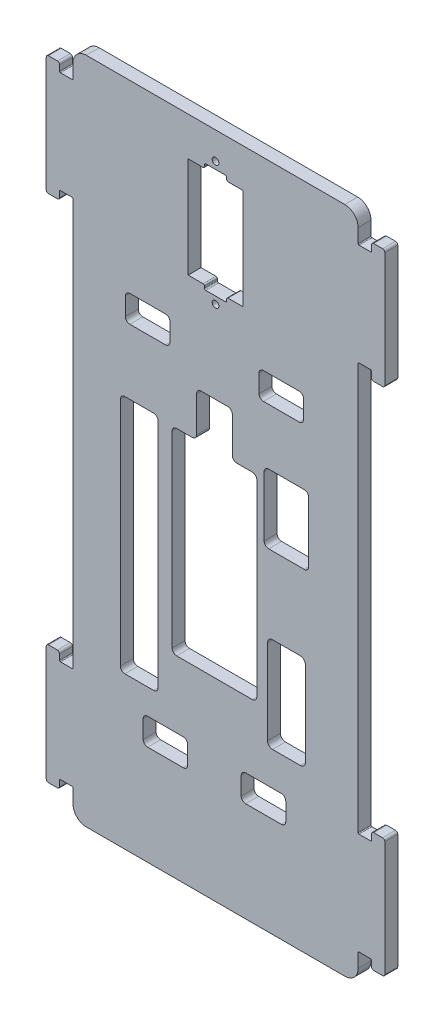
from build123d import *

# Parameters (mm, degrees)
EXTRUDE_1_DEPTH     = 1.45
SKETCH_2_R          = 0.75
SKETCH_2_W          = 12.3
SKETCH_2_H          = 22.6
CUT_EXTRUDE_1_DEPTH = 3.9
SKETCH_3_W          = 5
SKETCH_3_H          = 1
CUT_EXTRUDE_2_DEPTH = 3.9
FILLET_1_R          = 0.3
CUT_EXTRUDE_3_DEPTH = 3.9
CUT_EXTRUDE_4_DEPTH = 3.9
FILLET_2_R          = 1
CUT_EXTRUDE_5_DEPTH = 3.9


with BuildPart() as part:
    # 草图1 → 凸台-拉伸1 (new body, symmetric)
    with BuildSketch(Plane.XY):
        with BuildLine():
            Line((32.2, 68.7), (34.8, 68.7))
            ThreePointArc((34.8, 68.7), (34.941421356, 68.758578644), (35, 68.9))
            Line((35, 68.9), (35, 70.15))
            ThreePointArc((35, 70.15), (35.146446609, 70.503553391), (35.5, 70.65))
            Line((35.5, 70.65), (37.5, 70.65))
            ThreePointArc((37.5, 70.65), (37.853553391, 70.503553391), (38, 70.15))
            Line((38, 70.15), (38, 44.35))
            ThreePointArc((38, 44.35), (37.853553391, 43.996446609), (37.5, 43.85))
            Line((37.5, 43.85), (35.5, 43.85))
            ThreePointArc((35.5, 43.85), (35.146446609, 43.996446609), (35, 44.35))
            Line((35, 44.35), (35, 45.6))
            ThreePointArc((35, 45.6), (34.941421356, 45.741421356), (34.8, 45.8))
            Line((34.8, 45.8), (32.2, 45.8))
            ThreePointArc((32.2, 45.8), (32.058578644, 45.741421356), (32, 45.6))
            Line((32, 45.6), (32, -45.6))
            ThreePointArc((32, -45.6), (32.058578644, -45.741421356), (32.2, -45.8))
            Line((32.2, -45.8), (34.8, -45.8))
            ThreePointArc((34.8, -45.8), (34.941421356, -45.741421356), (35, -45.6))
            Line((35, -45.6), (35, -44.35))
            ThreePointArc((35, -44.35), (35.146446609, -43.996446609), (35.5, -43.85))
            Line((35.5, -43.85), (37.5, -43.85))
            ThreePointArc((37.5, -43.85), (37.853553391, -43.996446609), (38, -44.35))
            Line((38, -44.35), (38, -70.15))
            ThreePointArc((38, -70.15), (37.853553391, -70.503553391), (37.5, -70.65))
            Line((37.5, -70.65), (35.5, -70.65))
            ThreePointArc((35.5, -70.65), (35.146446609, -70.503553391), (35, -70.15))
            Line((35, -70.15), (35, -68.9))
            ThreePointArc((35, -68.9), (34.941421356, -68.758578644), (34.8, -68.7))
            Line((34.8, -68.7), (32.2, -68.7))
            ThreePointArc((32.2, -68.7), (32.058578644, -68.758578644), (32, -68.9))
            Line((32, -68.9), (32, -72))
            ThreePointArc((32, -72), (31.121320344, -74.121320344), (29, -75))
            Line((29, -75), (-29, -75))
            ThreePointArc((-29, -75), (-31.121320344, -74.121320344), (-32, -72))
            Line((-32, -72), (-32, -68.9))
            ThreePointArc((-32, -68.9), (-32.058578644, -68.758578644), (-32.2, -68.7))
            Line((-32.2, -68.7), (-34.8, -68.7))
            ThreePointArc((-34.8, -68.7), (-34.941421356, -68.758578644), (-35, -68.9))
            Line((-35, -68.9), (-35, -70.15))
            ThreePointArc((-35, -70.15), (-35.146446609, -70.503553391), (-35.5, -70.65))
            Line((-35.5, -70.65), (-37.5, -70.65))
            ThreePointArc((-37.5, -70.65), (-37.853553391, -70.503553391), (-38, -70.15))
            Line((-38, -70.15), (-38, -44.35))
            ThreePointArc((-38, -44.35), (-37.853553391, -43.996446609), (-37.5, -43.85))
            Line((-37.5, -43.85), (-35.5, -43.85))
            ThreePointArc((-35.5, -43.85), (-35.146446609, -43.996446609), (-35, -44.35))
            Line((-35, -44.35), (-35, -45.6))
            ThreePointArc((-35, -45.6), (-34.941421356, -45.741421356), (-34.8, -45.8))
            Line((-34.8, -45.8), (-32.2, -45.8))
            ThreePointArc((-32.2, -45.8), (-32.058578644, -45.741421356), (-32, -45.6))
            Line((-32, -45.6), (-32, 45.6))
            ThreePointArc((-32, 45.6), (-32.058578644, 45.741421356), (-32.2, 45.8))
            Line((-32.2, 45.8), (-34.8, 45.8))
            ThreePointArc((-34.8, 45.8), (-34.941421356, 45.741421356), (-35, 45.6))
            Line((-35, 45.6), (-35, 44.35))
            ThreePointArc((-35, 44.35), (-35.146446609, 43.996446609), (-35.5, 43.85))
            Line((-35.5, 43.85), (-37.5, 43.85))
            ThreePointArc((-37.5, 43.85), (-37.853553391, 43.996446609), (-38, 44.35))
            Line((-38, 44.35), (-38, 70.15))
            ThreePointArc((-38, 70.15), (-37.853553391, 70.503553391), (-37.5, 70.65))
            Line((-37.5, 70.65), (-35.5, 70.65))
            ThreePointArc((-35.5, 70.65), (-35.146446609, 70.503553391), (-35, 70.15))
            Line((-35, 70.15), (-35, 68.9))
            ThreePointArc((-35, 68.9), (-34.941421356, 68.758578644), (-34.8, 68.7))
            Line((-34.8, 68.7), (-32.2, 68.7))
            ThreePointArc((-32.2, 68.7), (-32.058578644, 68.758578644), (-32, 68.9))
            Line((-32, 68.9), (-32, 72))
            ThreePointArc((-32, 72), (-31.121320344, 74.121320344), (-29, 75))
            Line((-29, 75), (29, 75))
            ThreePointArc((29, 75), (31.121320344, 74.121320344), (32, 72))
            Line((32, 72), (32, 68.9))
            ThreePointArc((32, 68.9), (32.058578644, 68.758578644), (32.2, 68.7))
        make_face()
    extrude(amount=EXTRUDE_1_DEPTH, both=True)

    # 草图2 → 切除-拉伸1 (cut, through all)
    with BuildSketch(Plane.XY.offset(1.45)):
        with Locations((0, 41.1)):
            Circle(SKETCH_2_R)
        with Locations((0, 68.9)):
            Circle(SKETCH_2_R)
        with Locations((0, 55)):
            Rectangle(SKETCH_2_W, SKETCH_2_H)
    extrude(amount=-CUT_EXTRUDE_1_DEPTH, mode=Mode.SUBTRACT)

    # 草图3 → 切除-拉伸2 (cut, through all)
    with BuildSketch(Plane.XY.offset(1.45)):
        with Locations((0, 66.8)):
            Rectangle(SKETCH_3_W, SKETCH_3_H)
        with Locations((0, 43.2)):
            Rectangle(SKETCH_3_W, SKETCH_3_H)
    extrude(amount=-CUT_EXTRUDE_2_DEPTH, mode=Mode.SUBTRACT)

    # 圆角1
    fillet_1_edges = [part.edges().sort_by_distance(p)[0] for p in [
        (2.5, 66.3, 0),
        (-2.5, 66.3, 0),
        (-2.5, 67.3, 0),
        (2.5, 67.3, 0),
        (-2.5, 43.7, 0),
        (2.5, 43.7, 0),
        (2.5, 42.7, 0),
        (-2.5, 42.7, 0),
    ]]
    fillet(fillet_1_edges, radius=FILLET_1_R)

    # 草图4 → 切除-拉伸3 (cut, through all)
    with BuildSketch(Plane.XY.offset(1.45)):
        with BuildLine():
            Line((-20.36, 12.99), (-13.89, 12.99))
            ThreePointArc((-13.89, 12.99), (-13.182893219, 12.697106781), (-12.89, 11.99))
            Line((-12.89, 11.99), (-12.89, -39.9))
            ThreePointArc((-12.89, -39.9), (-13.182893219, -40.607106781), (-13.89, -40.9))
            Line((-13.89, -40.9), (-20.36, -40.9))
            ThreePointArc((-20.36, -40.9), (-21.067106781, -40.607106781), (-21.36, -39.9))
            Line((-21.36, -39.9), (-21.36, 11.99))
            ThreePointArc((-21.36, 11.99), (-21.067106781, 12.697106781), (-20.36, 12.99))
        make_face()
        with BuildLine():
            Line((-8.74, 12.6), (8.26, 12.6))
            ThreePointArc((8.26, 12.6), (8.967106781, 12.307106781), (9.26, 11.6))
            Line((9.26, 11.6), (9.26, -30.6))
            ThreePointArc((9.26, -30.6), (8.967106781, -31.307106781), (8.26, -31.6))
            Line((8.26, -31.6), (-8.74, -31.6))
            ThreePointArc((-8.74, -31.6), (-9.447106781, -31.307106781), (-9.74, -30.6))
            Line((-9.74, -30.6), (-9.74, 11.6))
            ThreePointArc((-9.74, 11.6), (-9.447106781, 12.307106781), (-8.74, 12.6))
        make_face()
        with BuildLine():
            Line((11.91, 15.03), (19.91, 15.03))
            ThreePointArc((19.91, 15.03), (20.617106781, 14.737106781), (20.91, 14.03))
            Line((20.91, 14.03), (20.91, 0.53))
            ThreePointArc((20.91, 0.53), (20.617106781, -0.177106781), (19.91, -0.47))
            Line((19.91, -0.47), (11.91, -0.47))
            ThreePointArc((11.91, -0.47), (11.202893219, -0.177106781), (10.91, 0.53))
            Line((10.91, 0.53), (10.91, 14.03))
            ThreePointArc((10.91, 14.03), (11.202893219, 14.737106781), (11.91, 15.03))
        make_face()
        with BuildLine():
            Line((12.801778644, -17.71), (19.028221356, -17.71))
            ThreePointArc((19.028221356, -17.71), (19.821438642, -18.038561358), (20.15, -18.831778644))
            Line((20.15, -18.831778644), (20.15, -37.908221356))
            ThreePointArc((20.15, -37.908221356), (19.821438642, -38.701438642), (19.028221356, -39.03))
            Line((19.028221356, -39.03), (12.801778644, -39.03))
            ThreePointArc((12.801778644, -39.03), (12.008561358, -38.701438642), (11.68, -37.908221356))
            Line((11.68, -37.908221356), (11.68, -18.831778644))
            ThreePointArc((11.68, -18.831778644), (12.008561358, -18.038561358), (12.801778644, -17.71))
        make_face()
    extrude(amount=-CUT_EXTRUDE_3_DEPTH, mode=Mode.SUBTRACT)

    # 草图5 → 切除-拉伸4 (cut, through all)
    with BuildSketch(Plane.XY.offset(1.45)):
        with BuildLine():
            Line((-3.24, 22.6), (2.76, 22.6))
            ThreePointArc((2.76, 22.6), (3.467106781, 22.307106781), (3.76, 21.6))
            Line((3.76, 21.6), (3.76, 12.6))
            Line((3.76, 12.6), (-4.24, 12.6))
            Line((-4.24, 12.6), (-4.24, 21.6))
            ThreePointArc((-4.24, 21.6), (-3.947106781, 22.307106781), (-3.24, 22.6))
        make_face()
    extrude(amount=-CUT_EXTRUDE_4_DEPTH, mode=Mode.SUBTRACT)

    # 圆角2
    fillet_2_edges = [part.edges().sort_by_distance(p)[0] for p in [
        (3.76, 12.6, 0),
        (-4.24, 12.6, 0),
    ]]
    fillet(fillet_2_edges, radius=FILLET_2_R)

    # 草图6 → 切除-拉伸5 (cut, through all)
    with BuildSketch(Plane.XY.offset(1.45)):
        with BuildLine():
            Line((10.76, 33.6), (18.76, 33.6))
            ThreePointArc((18.76, 33.6), (19.467106781, 33.307106781), (19.76, 32.6))
            Line((19.76, 32.6), (19.76, 28.6))
            ThreePointArc((19.76, 28.6), (19.467106781, 27.892893219), (18.76, 27.6))
            Line((18.76, 27.6), (10.76, 27.6))
            ThreePointArc((10.76, 27.6), (10.052893219, 27.892893219), (9.76, 28.6))
            Line((9.76, 28.6), (9.76, 32.6))
            ThreePointArc((9.76, 32.6), (10.052893219, 33.307106781), (10.76, 33.6))
        make_face()
        with BuildLine():
            Line((6.76, -46.6), (14.76, -46.6))
            ThreePointArc((14.76, -46.6), (15.467106781, -46.892893219), (15.76, -47.6))
            Line((15.76, -47.6), (15.76, -51.6))
            ThreePointArc((15.76, -51.6), (15.467106781, -52.307106781), (14.76, -52.6))
            Line((14.76, -52.6), (6.76, -52.6))
            ThreePointArc((6.76, -52.6), (6.052893219, -52.307106781), (5.76, -51.6))
            Line((5.76, -51.6), (5.76, -47.6))
            ThreePointArc((5.76, -47.6), (6.052893219, -46.892893219), (6.76, -46.6))
        make_face()
        with BuildLine():
            Line((-10.24, 32.6), (-10.24, 28.6))
            ThreePointArc((-10.24, 28.6), (-10.532893219, 27.892893219), (-11.24, 27.6))
            Line((-11.24, 27.6), (-19.24, 27.6))
            ThreePointArc((-19.24, 27.6), (-19.947106781, 27.892893219), (-20.24, 28.6))
            Line((-20.24, 28.6), (-20.24, 32.6))
            ThreePointArc((-20.24, 32.6), (-19.947106781, 33.307106781), (-19.24, 33.6))
            Line((-19.24, 33.6), (-11.24, 33.6))
            ThreePointArc((-11.24, 33.6), (-10.532893219, 33.307106781), (-10.24, 32.6))
        make_face()
        with BuildLine():
            Line((-6.24, -47.6), (-6.24, -51.6))
            ThreePointArc((-6.24, -51.6), (-6.532893219, -52.307106781), (-7.24, -52.6))
            Line((-7.24, -52.6), (-15.24, -52.6))
            ThreePointArc((-15.24, -52.6), (-15.947106781, -52.307106781), (-16.24, -51.6))
            Line((-16.24, -51.6), (-16.24, -47.6))
            ThreePointArc((-16.24, -47.6), (-15.947106781, -46.892893219), (-15.24, -46.6))
            Line((-15.24, -46.6), (-7.24, -46.6))
            ThreePointArc((-7.24, -46.6), (-6.532893219, -46.892893219), (-6.24, -47.6))
        make_face()
    extrude(amount=-CUT_EXTRUDE_5_DEPTH, mode=Mode.SUBTRACT)


solid = part.part
